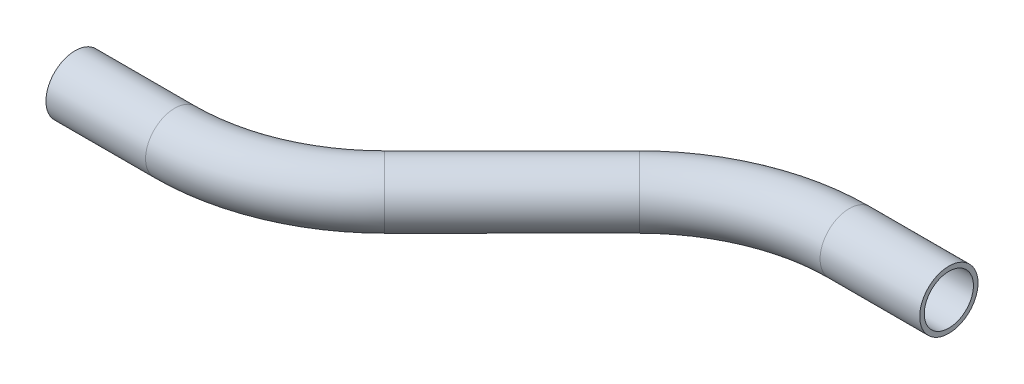
from build123d import *

# Parameters (mm, degrees)
SKETCH2_R   = 7.9375
SKETCH2_R_2 = 6.6929


with BuildPart() as part:
    # Sweep1: sweep along a path in Sketch1
    with BuildLine(Plane(origin=(0, 0, 0), x_dir=(1, 0, 0), z_dir=(0, 1, 0))) as sweep1_path:
        Line((0, 0), (27.12769491, 0))
        ThreePointArc((27.12769491, 0), (48.99805307, 4.350284717), (67.538847455, 16.738847455))
        Line((67.538847455, 16.738847455), (102.217293956, 51.417293956))
        ThreePointArc((102.217293956, 51.417293956), (120.758088342, 63.805856695), (142.628446501, 68.156141412))
        Line((142.628446501, 68.156141412), (169.756141412, 68.156141412))
    # Sketch2 → Sweep1 (sweep)
    with BuildSketch(Plane(origin=(0, 0, 0), x_dir=(0, 0, -1), z_dir=(1, 0, 0))):
        Circle(SKETCH2_R)
        Circle(SKETCH2_R_2, mode=Mode.SUBTRACT)
    sweep(path=sweep1_path.line)


solid = part.part
